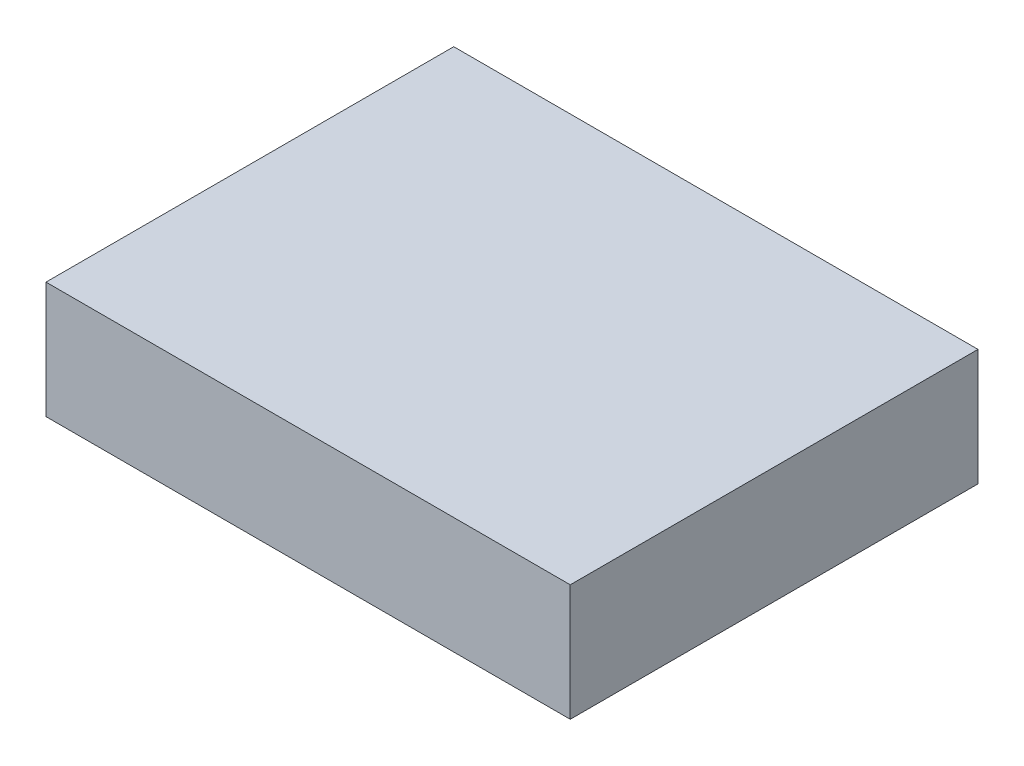
from build123d import *

# Parameters (mm, degrees)
SKETCH1_W           = 45.72
SKETCH1_H           = 35.56
BOSS_EXTRUDE1_DEPTH = 10.16


with BuildPart() as part:
    # Sketch1 → Boss-Extrude1 (new body)
    with BuildSketch(Plane(origin=(0, 0, 0), x_dir=(1, 0, 0), z_dir=(0, 1, 0))):
        Rectangle(SKETCH1_W, SKETCH1_H)
    extrude(amount=BOSS_EXTRUDE1_DEPTH)


solid = part.part
